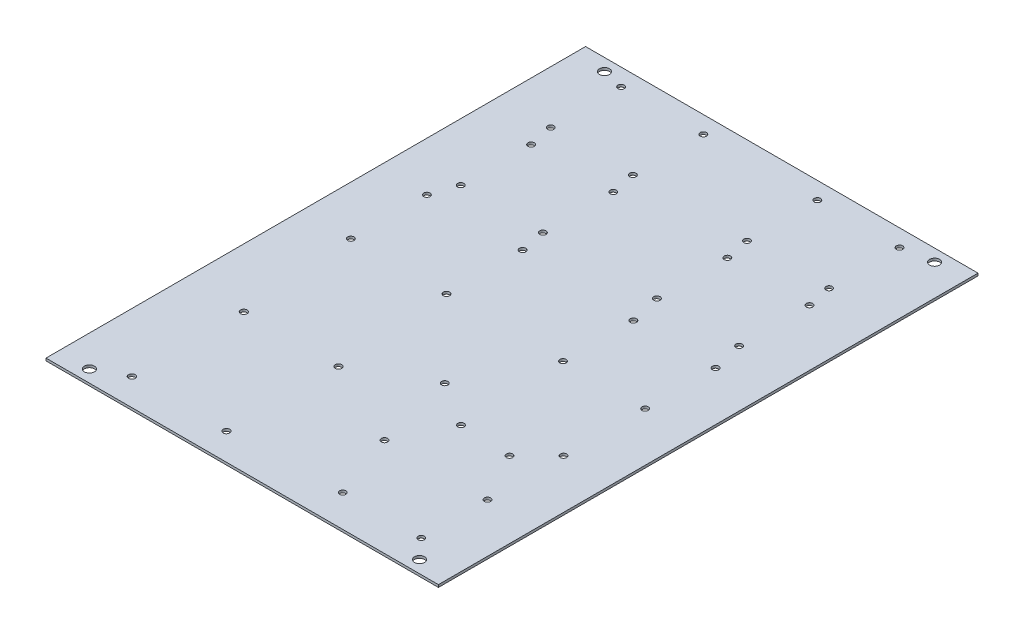
from build123d import *

# Parameters (mm, degrees)
SKETCH1_W                 = 203.2
SKETCH1_H                 = 279.4
BOSS_EXTRUDE1_DEPTH       = 1.27
MOUNTING_HOLES_D          = 5.1816
ROBOCLAW1_D               = 3.2639
RASPBERRY_PI_D            = 3.4
LPATTERN1_COUNT           = 2
LPATTERN1_PITCH           = 49.149
LPATTERN1_COUNT_DIR2      = 2
LPATTERN1_PITCH_DIR2      = 2.54
F_4_CLEARANCE_HOLE1_D     = 3.2639
F_4_CLEARANCE_HOLE1_DEPTH = 1.27
ENCODER_BOARD_D           = 3.2639
ENCODER_BOARD_DEPTH       = 1.27
F_12V_REG_D               = 3.2639
F_12V_REG_DEPTH           = 1.27
F_5V_REG_D                = 3.2639
F_5V_REG_DEPTH            = 1.27
LPATTERN2_COUNT           = 2
LPATTERN2_PITCH           = 101.6
LPATTERN3_COPY_1_D        = 3.2639
LPATTERN3_COPY_2_D        = 3.2639
SKETCH22_R                = 1.63195
READ_WRITE_BOARD_DEPTH    = 2.27


with BuildPart() as part:
    # Sketch1 → Boss-Extrude1 (new body)
    with BuildSketch(Plane(origin=(0, 0, 0), x_dir=(1, 0, 0), z_dir=(0, 1, 0))):
        Rectangle(SKETCH1_W, SKETCH1_H)
    extrude(amount=BOSS_EXTRUDE1_DEPTH)

    # Mounting Holes (through all)
    with Locations(Plane(origin=(0, 1.27, 0), x_dir=(1, 0, 0), z_dir=(0, 1, 0))):
        with Locations((-85.471, 133.35), (85.471, 133.35), (85.471, -133.35), (-85.471, -133.35)):
            Hole(MOUNTING_HOLES_D / 2)

    # RoboClaw1 (through all)
    with Locations(Plane(origin=(0, 1.27, 0), x_dir=(1, 0, 0), z_dir=(0, 1, 0))):
        with Locations((69.85, 130.81), (69.85, 94.361), (27.305, 94.361), (27.305, 130.81)):
            roboclaw1 = Hole(ROBOCLAW1_D / 2)

    # Raspberry Pi (through all)
    with Locations(Plane(origin=(0, 1.27, 0), x_dir=(1, 0, 0), z_dir=(0, 1, 0))):
        with Locations((-71.12, -125.73), (-22.12086, -125.73), (-22.12086, -67.7291), (-71.12, -67.7291)):
            Hole(RASPBERRY_PI_D / 2)

    # LPattern1: RoboClaw1 2 × 2, 2 skipped
    with Locations(*[(j * LPATTERN1_PITCH_DIR2, 0, i * LPATTERN1_PITCH) for i in range(LPATTERN1_COUNT) for j in range(LPATTERN1_COUNT_DIR2) if (i, j) not in ((0, 0), (0, 1), (1, 0))]):
        add(roboclaw1, mode=Mode.SUBTRACT)

    # #4 Clearance Hole1
    with Locations(Plane(origin=(0, 1.27, 0), x_dir=(1, 0, 0), z_dir=(0, 1, 0))):
        with Locations((33.655, 29.21), (76.2, 29.21), (76.2, -7.239), (33.655, -7.239)):
            Hole(F_4_CLEARANCE_HOLE1_D / 2, depth=F_4_CLEARANCE_HOLE1_DEPTH)

    # Encoder Board
    with Locations(Plane(origin=(0, 1.27, 0), x_dir=(1, 0, 0), z_dir=(0, 1, 0))):
        with Locations((-76.2, 32.131), (-26.67, 32.131), (-26.67, -7.239), (-76.2, -7.239), (33.655, -7.239)):
            Hole(ENCODER_BOARD_D / 2, depth=ENCODER_BOARD_DEPTH)

    # 12V Reg
    with Locations(Plane(origin=(0, 1.27, 0), x_dir=(1, 0, 0), z_dir=(0, 1, 0))):
        with Locations((22.86, -88.9), (76.2, -88.9), (35.56, -123.19), (76.2, -123.19)):
            Hole(F_12V_REG_D / 2, depth=F_12V_REG_DEPTH)

    # 5V Reg
    with Locations(Plane(origin=(0, 1.27, 0), x_dir=(1, 0, 0), z_dir=(0, 1, 0))):
        with Locations((62.23, -63.5), (76.2, -49.53)):
            Hole(F_5V_REG_D / 2, depth=F_5V_REG_DEPTH)

    # LPattern2: RoboClaw1 ×2
    with Locations(*[(-i * LPATTERN2_PITCH, 0, 0) for i in range(1, LPATTERN2_COUNT)]):
        add(roboclaw1, mode=Mode.SUBTRACT)

    # LPattern3 copy 1 (through all)
    with Locations(Plane(origin=(-99.06, 1.27, 49.149), x_dir=(1, 0, 0), z_dir=(0, 1, 0))):
        with Locations((69.85, 130.81), (69.85, 94.361), (27.305, 94.361), (27.305, 130.81)):
            Hole(LPATTERN3_COPY_1_D / 2)

    # LPattern3 copy 2 (through all)
    with Locations(Plane(origin=(2.54, 1.27, 49.149), x_dir=(1, 0, 0), z_dir=(0, 1, 0))):
        with Locations((69.85, 130.81), (69.85, 94.361), (27.305, 94.361), (27.305, 130.81)):
            Hole(LPATTERN3_COPY_2_D / 2)

    # Sketch22 → Read/Write Board (cut, through all)
    with BuildSketch(Plane(origin=(0, 1.27, 0), x_dir=(1, 0, 0), z_dir=(0, 1, 0))):
        with Locations((12.913142098, -47.716166247)):
            Circle(SKETCH22_R)
        with Locations((35.900142098, -62.321166247)):
            Circle(SKETCH22_R)
    extrude(amount=-READ_WRITE_BOARD_DEPTH, mode=Mode.SUBTRACT)


solid = part.part
